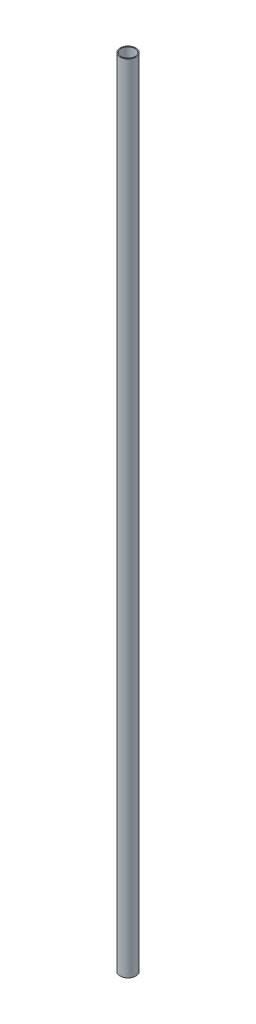
from build123d import *

# Parameters (mm, degrees)
SKETCH1_R           = 4
SKETCH1_R_2         = 3.5
BOSS_EXTRUDE1_DEPTH = 400


with BuildPart() as part:
    # Sketch1 → Boss-Extrude1 (new body)
    with BuildSketch(Plane(origin=(0, 0, 0), x_dir=(1, 0, 0), z_dir=(0, 1, 0))):
        Circle(SKETCH1_R)
        Circle(SKETCH1_R_2, mode=Mode.SUBTRACT)
    extrude(amount=BOSS_EXTRUDE1_DEPTH)


solid = part.part
